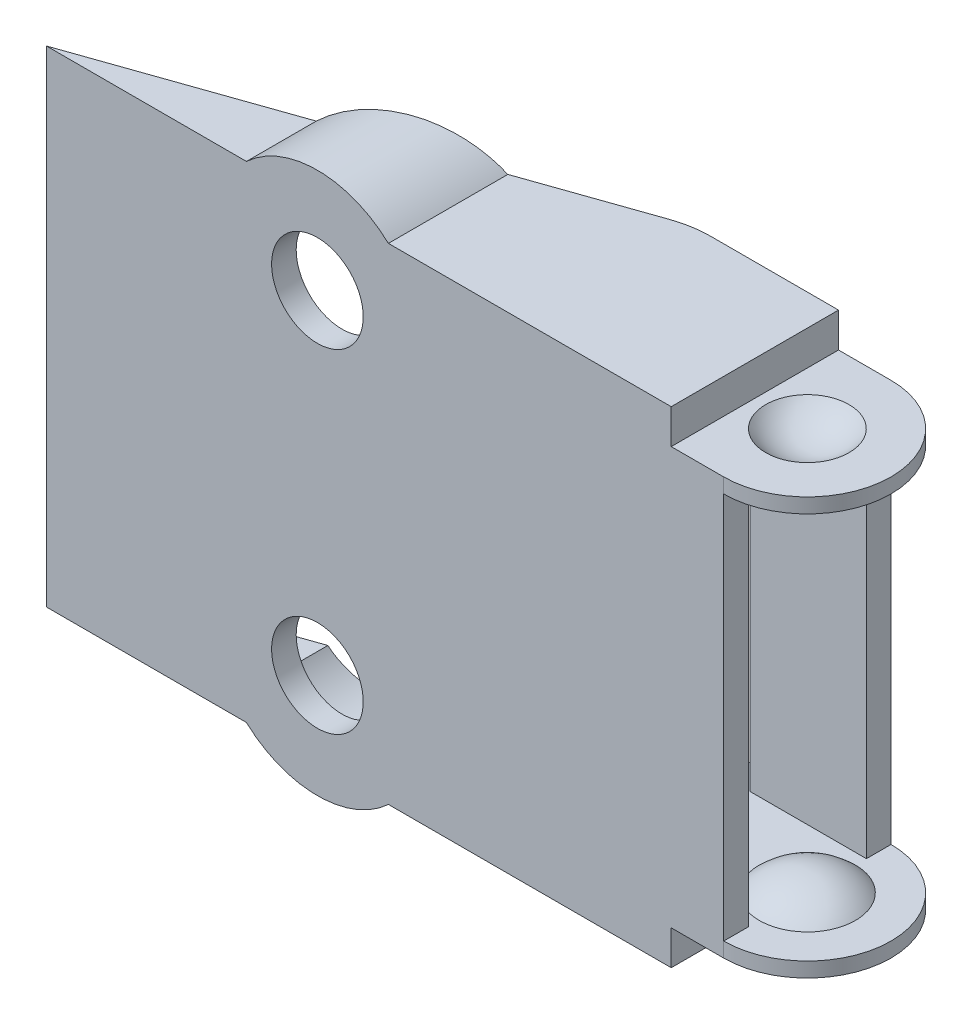
from build123d import *

# Parameters (mm, degrees)
BOSS_EXTRUDE2_DEPTH = 2.1082
BOSS_EXTRUDE3_DEPTH = 0.9
SKETCH13_W          = 8.400608993
SKETCH13_H          = 1.5
BOSS_EXTRUDE4_DEPTH = 12.7
SKETCH16_W          = 7.09322036
SKETCH16_H          = 1.5
BOSS_EXTRUDE5_DEPTH = 11.8
BOSS_EXTRUDE6_DEPTH = 2.1082
BOSS_EXTRUDE7_REACH = 45.656
BOSS_EXTRUDE8_DEPTH = 2.1082
FILLET1_R           = 6.35
SKETCH20_R          = 2.794
CUT_EXTRUDE1_DEPTH  = 46.30015706
SKETCH21_R          = 4.572
CUT_EXTRUDE2_DEPTH  = 46.30015706
BOSS_EXTRUDE9_REACH = 47.612


with BuildPart() as part:
    # Sketch6 → Boss-Extrude2 (new body)
    with BuildSketch(Plane(origin=(0, 0, 0), x_dir=(1, 0, 0), z_dir=(0, 1, 0))):
        with BuildLine():
            Line((3.1496, 3.175), (3.1496, 8.27377964))
            Line((3.1496, 8.27377964), (-5.741348421, 8.27377964))
            Line((-5.741348421, 8.27377964), (-8.59506403, 5.42006403))
            ThreePointArc((-8.59506403, 5.42006403), (-9.283317516, 4.390019898), (-9.525, 3.175))
            Line((-9.525, 3.175), (-9.525, -1.92377964))
            Line((-9.525, -1.92377964), (-6.989909723, -1.92377964))
            Line((-6.989909723, -1.92377964), (3.1496, -1.92377964))
            Line((3.1496, -1.92377964), (3.1496, 3.175))
        make_face()
    extrude(amount=BOSS_EXTRUDE2_DEPTH)

    # Sketch7 → Boss-Extrude3 (add)
    with BuildSketch(Plane.XZ):
        with BuildLine():
            Line((-2.050608993, 1.92377964), (-2.050608993, 0.42377964))
            ThreePointArc((-2.050608993, 0.42377964), (-0.881374643, -4.411978027), (-4.017957094, -8.27377964))
            Line((-4.017957094, -8.27377964), (6.35, -8.27377964))
            ThreePointArc((6.35, -8.27377964), (11.44877964, -3.175), (6.35, 1.92377964))
            Line((6.35, 1.92377964), (-2.050608993, 1.92377964))
        make_face()
    extrude(amount=BOSS_EXTRUDE3_DEPTH)

    # Sketch11 → Revolve4 (revolve)
    with BuildSketch(Plane.XY.offset(-3.175), mode=Mode.PRIVATE) as revolve4_sk:
        with BuildLine():
            Line((6.35, -0.9), (6.35, -2.083581452))
            ThreePointArc((6.35, -2.083581452), (7.929346537, -1.776499661), (9.278562256, -0.9))
            Line((9.278562256, -0.9), (6.35, -0.9))
        make_face()
    revolve(revolve4_sk.sketch.rotate(Axis((6.35, -0.9, -3.175), (0, -1, 0)), 180), axis=Axis((6.35, -0.9, -3.175), (0, -1, 0)))

    # Sketch12 → Cut-Revolve1 (revolve, cut)
    with BuildSketch(Plane.XY.offset(-3.175), mode=Mode.PRIVATE) as cut_revolve1_sk:
        with BuildLine():
            Line((8.89, 0), (6.35, 0))
            Line((6.35, 0), (6.35, -1.184421452))
            ThreePointArc((6.35, -1.184421452), (7.751289957, -0.873762947), (8.89, 0))
        make_face()
    revolve(cut_revolve1_sk.sketch.rotate(Axis((6.35, 0, -3.175), (0, -1, 0)), 180), axis=Axis((6.35, 0, -3.175), (0, -1, 0)), mode=Mode.SUBTRACT)

    # Sketch13 → Boss-Extrude4 (add)
    with BuildSketch(Plane.XZ):
        with Locations((2.149695504, 1.17377964)):
            Rectangle(SKETCH13_W, SKETCH13_H)
    extrude(amount=BOSS_EXTRUDE4_DEPTH)

    # Sketch16 → Boss-Extrude5 (add)
    with BuildSketch(Plane.XZ.offset(0.9)):
        with Locations((2.80338982, -7.52377964)):
            Rectangle(SKETCH16_W, SKETCH16_H)
    extrude(amount=BOSS_EXTRUDE5_DEPTH)

    # Mirror1: part across plane


with BuildPart() as part_1:
    add(part.part)
    add(part.part.mirror(Plane(origin=(6.35, -12.7, 1.92377964), x_dir=(0, 0, 1), z_dir=(0, 1, 0))))

    # Sketch17 → Boss-Extrude6 (add)
    with BuildSketch(Plane.XZ.offset(27.5082)):
        with BuildLine():
            Line((-5.741348421, -8.27377964), (-34.925, 1.92377964))
            Line((-34.925, 1.92377964), (-9.525, 1.92377964))
            Line((-9.525, 1.92377964), (-9.525, -3.175))
            ThreePointArc((-9.525, -3.175), (-9.283317516, -4.390019898), (-8.59506403, -5.42006403))
            Line((-8.59506403, -5.42006403), (-5.741348421, -8.27377964))
        make_face()
    extrude(amount=-BOSS_EXTRUDE6_DEPTH)

    # Boss-Extrude7: up to this face of the body (flat: up to its plane)
    boss_extrude7_end = Plane(part_1.part.faces().sort_by_distance((-20.33317421, -26.4541, -3.175))[0])
    # Sketch18 → Boss-Extrude7 (add, up to the picked face)
    with BuildSketch(Plane.ZY.offset(2.050608993), mode=Mode.PRIVATE) as boss_extrude7_sk1:
        Polygon((1.92377964, 0), (0.42377964, 0), (0.42377964, -0.9), (0.42377964, -24.5), (0.42377964, -25.4), (1.92377964, -25.4), align=None)
    boss_extrude7_tool1 = split(extrude(boss_extrude7_sk1.sketch, amount=BOSS_EXTRUDE7_REACH, mode=Mode.PRIVATE), bisect_by=boss_extrude7_end, keep=Keep.BOTH, mode=Mode.PRIVATE)
    add(boss_extrude7_tool1.solids().sort_by(Axis((-2.050609, -12.7, 1.17378), (-1, 0, 0)))[0])

    # Sketch19 → Boss-Extrude8 (add)
    with BuildSketch(Plane(origin=(0, 2.1082, 0), x_dir=(1, 0, 0), z_dir=(0, 1, 0))):
        with BuildLine():
            Line((-5.741348421, 8.27377964), (-30.632259338, -0.42377964))
            Line((-30.632259338, -0.42377964), (-9.525, -0.42377964))
            Line((-9.525, -0.42377964), (-9.525, 3.175))
            ThreePointArc((-9.525, 3.175), (-9.283317516, 4.390019898), (-8.59506403, 5.42006403))
            Line((-8.59506403, 5.42006403), (-5.741348421, 8.27377964))
        make_face()
        Polygon((-9.525, -0.42377964), (-30.632259338, -0.42377964), (-34.925, -1.92377964), (-9.525, -1.92377964), align=None)
    extrude(amount=-BOSS_EXTRUDE8_DEPTH)

    # Fillet1
    fillet1_edges = [part_1.edges().sort_by_distance(p)[0] for p in [
        (-5.741348421, 1.0541, -8.27377964),
        (-5.741348421, -26.4541, -8.27377964),
    ]]
    fillet(fillet1_edges, radius=FILLET1_R)

    # Sketch20 → Cut-Extrude1 (cut, through all)
    with BuildSketch(Plane(origin=(0, 0, 0.42377964), x_dir=(-1, 0, 0), z_dir=(0, 0, -1))):
        with Locations((18.415, -22.86)):
            Circle(SKETCH20_R)
        with Locations((18.415, -2.54)):
            Circle(SKETCH20_R)
    extrude(amount=-CUT_EXTRUDE1_DEPTH, mode=Mode.SUBTRACT)

    # Sketch21 → Cut-Extrude2 (cut, through all)
    with BuildSketch(Plane(origin=(0, 0, 0.42377964), x_dir=(-1, 0, 0), z_dir=(0, 0, -1))):
        with Locations((18.415, -22.86)):
            Circle(SKETCH21_R)
        with Locations((18.415, -2.54)):
            Circle(SKETCH21_R)
    extrude(amount=CUT_EXTRUDE2_DEPTH, mode=Mode.SUBTRACT)

    # Boss-Extrude9: up to this plane
    boss_extrude9_end = Plane(origin=(-5.741348421, 5.514005479, -8.27377964), z_dir=(-0.3298685861491406, 0, -0.9440268618381402))
    # Sketch22 → Boss-Extrude9 (add, up to the surface)
    with BuildSketch(Plane.XY.offset(1.92377964), mode=Mode.PRIVATE) as boss_extrude9_sk1:
        with BuildLine():
            Line((-14.088715594, -27.5082), (-22.741284406, -27.5082))
            ThreePointArc((-22.741284406, -27.5082), (-18.415, -29.21), (-14.088715594, -27.5082))
        make_face()
    boss_extrude9_tool1 = split(extrude(boss_extrude9_sk1.sketch, amount=-BOSS_EXTRUDE9_REACH, mode=Mode.PRIVATE), bisect_by=boss_extrude9_end, keep=Keep.BOTH, mode=Mode.PRIVATE)
    add(boss_extrude9_tool1.solids().sort_by_distance((-18.415, -28.197399, 1.92378))[0])
    # Sketch22 → Boss-Extrude9 (add, up to the surface)
    with BuildSketch(Plane.XY.offset(1.92377964), mode=Mode.PRIVATE) as boss_extrude9_sk2:
        with BuildLine():
            Line((-22.741284406, 2.1082), (-14.088715594, 2.1082))
            ThreePointArc((-14.088715594, 2.1082), (-18.415, 3.81), (-22.741284406, 2.1082))
        make_face()
    boss_extrude9_tool2 = split(extrude(boss_extrude9_sk2.sketch, amount=-BOSS_EXTRUDE9_REACH, mode=Mode.PRIVATE), bisect_by=boss_extrude9_end, keep=Keep.BOTH, mode=Mode.PRIVATE)
    add(boss_extrude9_tool2.solids().sort_by_distance((-18.415, 2.797399, 1.92378))[0])


solid = part_1.part
